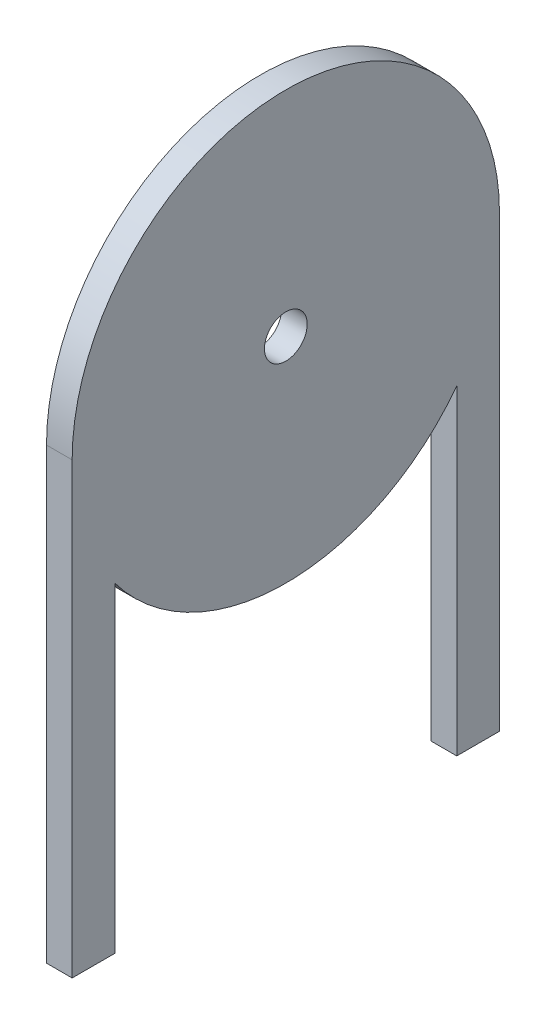
from build123d import *

# Parameters (mm, degrees)
SKETCH1_R           = 2.5
BOSS_EXTRUDE1_DEPTH = 3


with BuildPart() as part:
    # Sketch1 → Boss-Extrude1 (new body)
    with BuildSketch(Plane(origin=(0, 0, 0), x_dir=(0, 0, -1), z_dir=(1, 0, 0))):
        with BuildLine():
            ThreePointArc((-20, -15), (-23.717082451, -7.90569415), (-25, 0))
            Line((-25, 0), (-25, -52.5))
            Line((-25, -52.5), (-20, -52.5))
            Line((-20, -52.5), (-20, -15))
        make_face()
        with BuildLine():
            ThreePointArc((25, 0), (0, 25), (-25, 0))
            ThreePointArc((-25, 0), (-23.717082451, -7.90569415), (-20, -15))
            ThreePointArc((-20, -15), (0, -25), (20, -15))
            ThreePointArc((20, -15), (23.717082451, -7.90569415), (25, 0))
        make_face()
        Circle(SKETCH1_R, mode=Mode.SUBTRACT)
        with BuildLine():
            Line((25, -52.5), (25, 0))
            ThreePointArc((25, 0), (23.717082451, -7.90569415), (20, -15))
            Line((20, -15), (20, -52.5))
            Line((20, -52.5), (25, -52.5))
        make_face()
    extrude(amount=BOSS_EXTRUDE1_DEPTH)


solid = part.part
